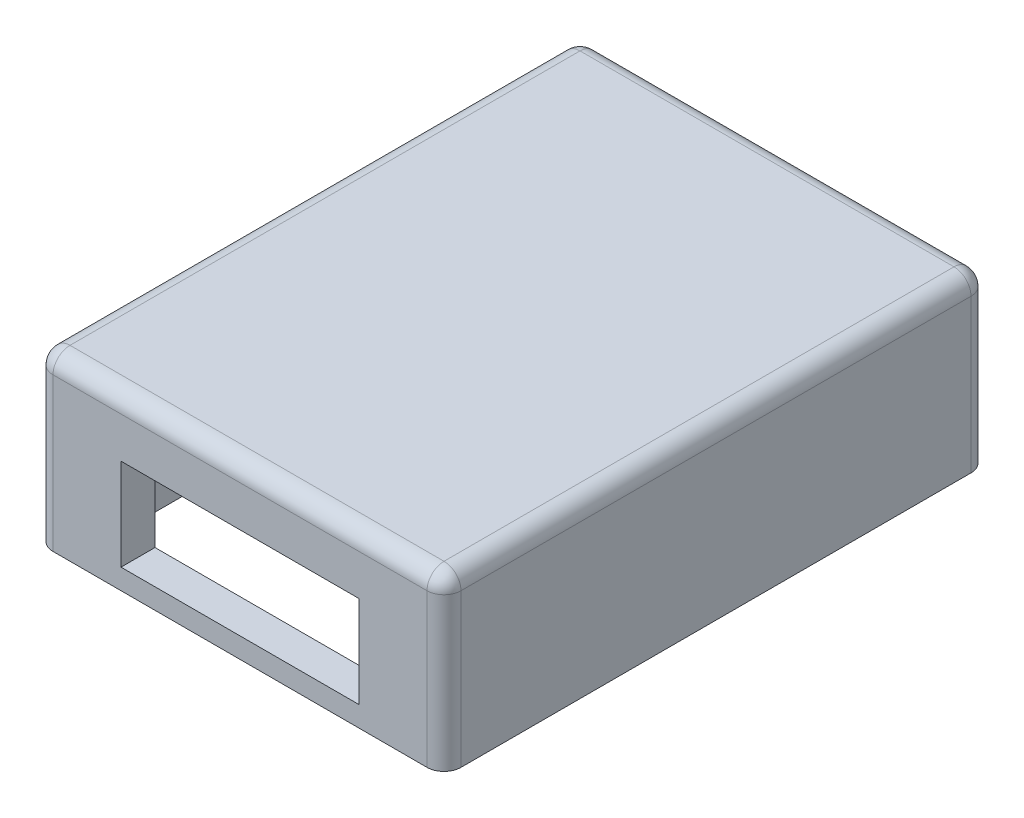
from build123d import *

# Parameters (mm, degrees)
SKETCH1_W           = 120
SKETCH1_H           = 50
BOSS_EXTRUDE1_DEPTH = 160
FILLET1_R           = 5
FILLET2_R           = 5
SKETCH2_W           = 100
SKETCH2_H           = 140
CUT_EXTRUDE1_DEPTH  = 45
FILLET3_R           = 5
FILLET4_R           = 5
FILLET5_R           = 5
SKETCH3_R           = 1.5
CUT_EXTRUDE2_DEPTH  = 20
SKETCH4_W           = 70
SKETCH4_H           = 27
CUT_EXTRUDE4_DEPTH  = 20


with BuildPart() as part:
    # Sketch1 → Boss-Extrude1 (new body)
    with BuildSketch(Plane.XY):
        with Locations((60, -25)):
            Rectangle(SKETCH1_W, SKETCH1_H)
    extrude(amount=BOSS_EXTRUDE1_DEPTH)

    # Fillet1
    fillet1_edges = [part.edges().sort_by_distance(p)[0] for p in [
        (0, -25, 160),
    ]]
    fillet(fillet1_edges, radius=FILLET1_R)

    # Fillet2
    fillet2_edges = [part.edges().sort_by_distance(p)[0] for p in [
        (120, -25, 160),
        (120, -25, 0),
        (0, -25, 0),
    ]]
    fillet(fillet2_edges, radius=FILLET2_R)

    # Sketch2 → Cut-Extrude1 (cut)
    with BuildSketch(Plane.XZ.offset(50)):
        with Locations((60, 80)):
            Rectangle(SKETCH2_W, SKETCH2_H)
    extrude(amount=-CUT_EXTRUDE1_DEPTH, mode=Mode.SUBTRACT)

    # Fillet3
    fillet3_edges = [part.edges().sort_by_distance(p)[0] for p in [
        (10, -27.5, 10),
        (10, -27.5, 150),
        (110, -27.5, 150),
        (110, -27.5, 10),
    ]]
    fillet(fillet3_edges, radius=FILLET3_R)

    # Fillet4
    fillet4_edges = [part.edges().sort_by_distance(p)[0] for p in [
        (110, -5, 80),
        (60, -5, 10),
        (10, -5, 80),
        (60, -5, 150),
        (11.464466094, -5, 148.535533906),
        (108.535533906, -5, 148.535533906),
        (11.464466094, -5, 11.464466094),
        (108.535533906, -5, 11.464466094),
    ]]
    fillet(fillet4_edges, radius=FILLET4_R)

    # Fillet5
    fillet5_edges = [part.edges().sort_by_distance(p)[0] for p in [
        (0, 0, 80),
        (1.464466094, 0, 158.535533906),
        (60, 0, 0),
        (60, 0, 160),
        (120, 0, 80),
        (118.535533906, 0, 158.535533906),
        (118.535533906, 0, 1.464466094),
        (1.464466094, 0, 1.464466094),
    ]]
    fillet(fillet5_edges, radius=FILLET5_R)

    # Sketch3 → Cut-Extrude2 (cut)
    with BuildSketch(Plane.XZ.offset(50)):
        with Locations((5, 155)):
            Circle(SKETCH3_R)
        with Locations((115, 155)):
            Circle(SKETCH3_R)
        with Locations((115, 5)):
            Circle(SKETCH3_R)
        with Locations((5, 5)):
            Circle(SKETCH3_R)
    extrude(amount=-CUT_EXTRUDE2_DEPTH, mode=Mode.SUBTRACT)

    # Sketch4 → Cut-Extrude4 (cut)
    with BuildSketch(Plane.XY.offset(160)):
        with Locations((60, -30.5)):
            Rectangle(SKETCH4_W, SKETCH4_H)
    extrude(amount=-CUT_EXTRUDE4_DEPTH, mode=Mode.SUBTRACT)


solid = part.part
